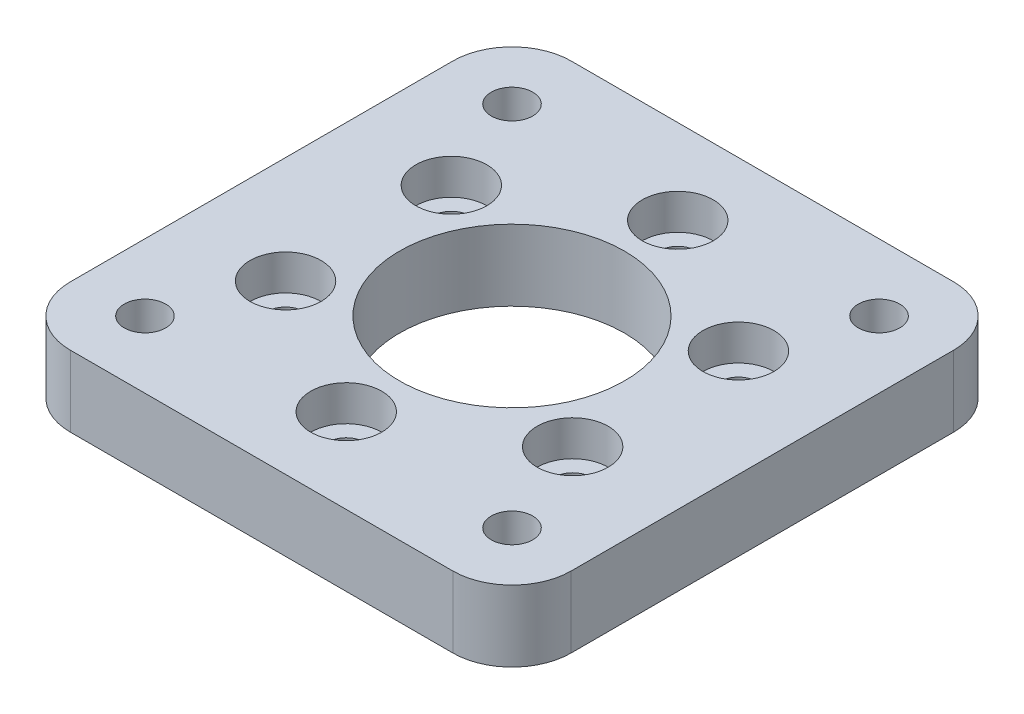
from build123d import *

# Parameters (mm, degrees)
SKETCH1_W           = 42.3
SKETCH1_H           = 42.3
BOSS_EXTRUDE1_DEPTH = 3
FILLET1_R           = 5
SKETCH2_R           = 1.75
CUT_EXTRUDE1_DEPTH  = 7
SKETCH4_R           = 9.5
CUT_EXTRUDE3_DEPTH  = 7
SKETCH5_R           = 1.55
CUT_EXTRUDE4_DEPTH  = 7
SKETCH6_R           = 3
CUT_EXTRUDE5_DEPTH  = 3
CIRPATTERN1_COUNT   = 6


with BuildPart() as part:
    # Sketch1 → Boss-Extrude1 (new body, symmetric)
    with BuildSketch(Plane(origin=(0, 0, 0), x_dir=(1, 0, 0), z_dir=(0, 1, 0))):
        Rectangle(SKETCH1_W, SKETCH1_H)
    extrude(amount=BOSS_EXTRUDE1_DEPTH, both=True)

    # Fillet1
    fillet1_edges = [part.edges().sort_by_distance(p)[0] for p in [
        (21.15, 0, 21.15),
        (-21.15, 0, 21.15),
        (-21.15, 0, -21.15),
        (21.15, 0, -21.15),
    ]]
    fillet(fillet1_edges, radius=FILLET1_R)

    # Sketch2 → Cut-Extrude1 (cut, through all)
    with BuildSketch(Plane.XZ.offset(3)):
        with Locations((-15.5, 15.5)):
            Circle(SKETCH2_R)
        with Locations((15.5, 15.5)):
            Circle(SKETCH2_R)
        with Locations((15.5, -15.5)):
            Circle(SKETCH2_R)
        with Locations((-15.5, -15.5)):
            Circle(SKETCH2_R)
    extrude(amount=-CUT_EXTRUDE1_DEPTH, mode=Mode.SUBTRACT)

    # Sketch4 → Cut-Extrude3 (cut, through all)
    with BuildSketch(Plane.XZ.offset(3)):
        Circle(SKETCH4_R)
    extrude(amount=-CUT_EXTRUDE3_DEPTH, mode=Mode.SUBTRACT)

    # Sketch5 → Cut-Extrude4 (cut, through all)
    with BuildSketch(Plane(origin=(0, 3, 0), x_dir=(1, 0, 0), z_dir=(0, 1, 0))):
        with Locations((0, 14)):
            Circle(SKETCH5_R)
    cut_extrude4 = extrude(amount=-CUT_EXTRUDE4_DEPTH, mode=Mode.SUBTRACT)

    # Sketch6 → Cut-Extrude5 (cut)
    with BuildSketch(Plane(origin=(0, 3, 0), x_dir=(1, 0, 0), z_dir=(0, 1, 0))):
        with Locations((0, 14)):
            Circle(SKETCH6_R)
    cut_extrude5 = extrude(amount=-CUT_EXTRUDE5_DEPTH, mode=Mode.SUBTRACT)

    # CirPattern1: Cut-Extrude4, Cut-Extrude5 ×6 about axis
    cirpattern1_axis = Axis((0, 0, 0), (0, 1, 0))
    for i in range(1, CIRPATTERN1_COUNT):
        add(cut_extrude4.rotate(cirpattern1_axis, i * 360 / CIRPATTERN1_COUNT), mode=Mode.SUBTRACT)
        add(cut_extrude5.rotate(cirpattern1_axis, i * 360 / CIRPATTERN1_COUNT), mode=Mode.SUBTRACT)


solid = part.part
